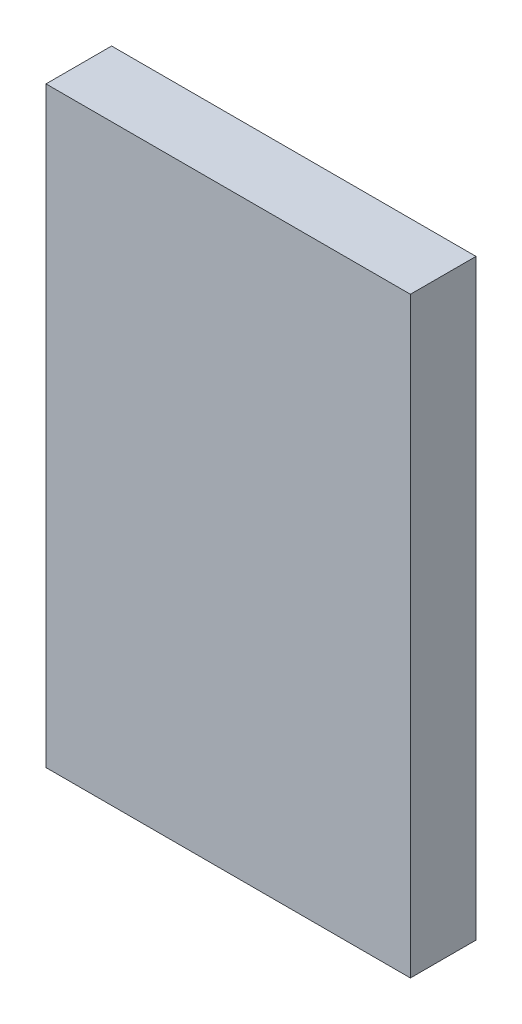
from build123d import *

# Parameters (mm, degrees)
SKETCH1_W           = 65
SKETCH1_H           = 40
BOSS_EXTRUDE1_DEPTH = 7.2


with BuildPart() as part:
    # Sketch1 → Boss-Extrude1 (new body)
    with BuildSketch(Plane(origin=(0, 0, 0), x_dir=(0, 1, 0), z_dir=(0, 0, 1))):
        with Locations((32.5, 20)):
            Rectangle(SKETCH1_W, SKETCH1_H)
    extrude(amount=BOSS_EXTRUDE1_DEPTH)


solid = part.part
